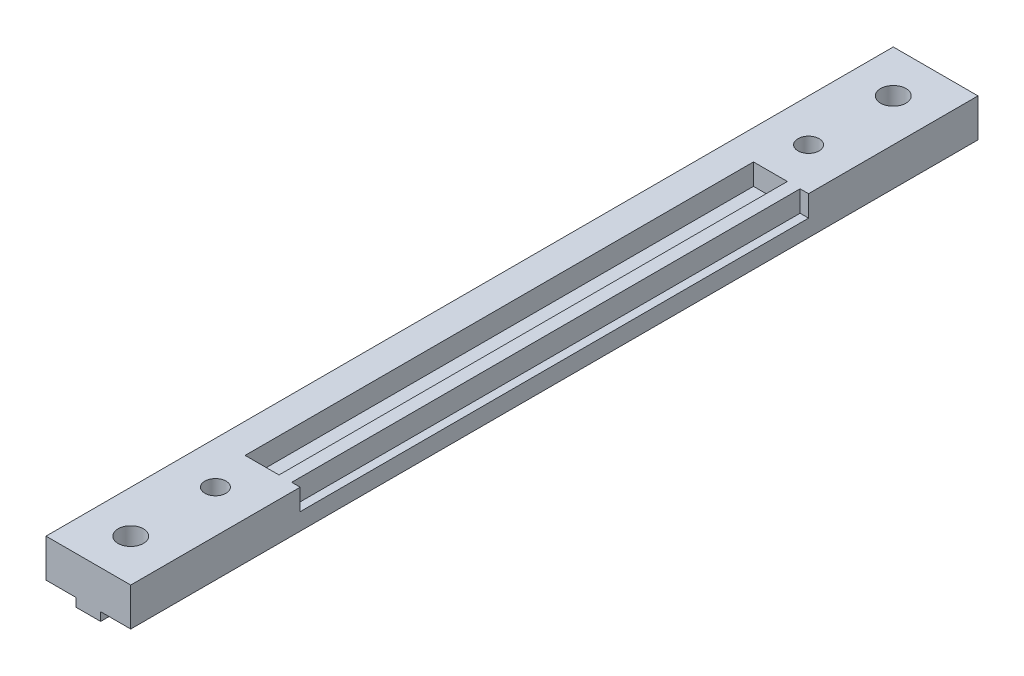
from build123d import *

# Parameters (mm, degrees)
MAIN_DEPTH      = 100
SKETCH2_R       = 1.25
SKETCH2_R_2     = 1.5
MAINHOLES_DEPTH = 6.5
SKETCH3_W       = 1
SKETCH3_H       = 60
SKETCH3_W_2     = 4
PINHOLES_DEPTH  = 2.5


with BuildPart() as part:
    # Sketch1 → Main (new body)
    with BuildSketch(Plane.XY):
        Polygon((-5, 0), (5, 0), (5, -4.5), (1.45, -4.5), (1.45, -5.5), (-1.45, -5.5), (-1.45, -4.5), (-5, -4.5), align=None)
    extrude(amount=MAIN_DEPTH)

    # Sketch2 → MainHoles (cut, through all)
    with BuildSketch(Plane(origin=(0, 0, 0), x_dir=(1, 0, 0), z_dir=(0, 1, 0))):
        with Locations((0, -85)):
            Circle(SKETCH2_R)
        with Locations((0, -15)):
            Circle(SKETCH2_R)
        with Locations((0, -5)):
            Circle(SKETCH2_R_2)
        with Locations((0, -95)):
            Circle(SKETCH2_R_2)
    extrude(amount=-MAINHOLES_DEPTH, mode=Mode.SUBTRACT)

    # Sketch3 → PinHoles (cut)
    with BuildSketch(Plane(origin=(0, 0, 0), x_dir=(1, 0, 0), z_dir=(0, 1, 0))):
        with Locations((4.5, -50)):
            Rectangle(SKETCH3_W, SKETCH3_H)
        with Locations((0.5, -50)):
            Rectangle(SKETCH3_W_2, SKETCH3_H)
    extrude(amount=-PINHOLES_DEPTH, mode=Mode.SUBTRACT)


solid = part.part
